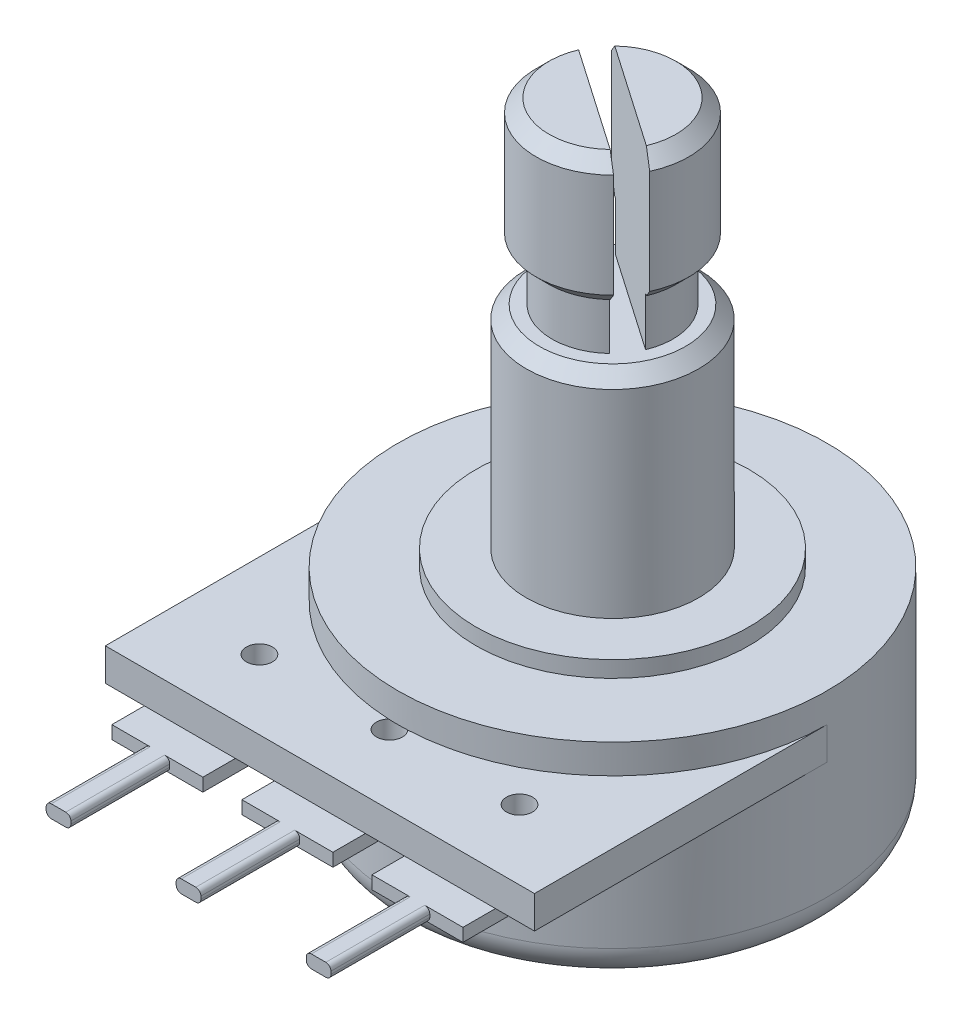
from build123d import *

# Parameters (mm, degrees)
SKETCH2_W           = 16.764
SKETCH2_H           = 1.27
BOSS_EXTRUDE1_DEPTH = 11.43
SKETCH3_R           = 0.508
BOSS_EXTRUDE2_DEPTH = 0.508
SKETCH5_R           = 8.382
SKETCH5_R_2         = 5.334
CUT_EXTRUDE2_DEPTH  = 15.875
LPATTERN1_COUNT     = 2
LPATTERN1_PITCH     = 5.08
LPATTERN2_COUNT     = 2
LPATTERN2_PITCH     = 5.08
SKETCH7_R           = 0.508
CUT_EXTRUDE3_DEPTH  = 1.27
CUT_EXTRUDE4_DEPTH  = 6.985
CHAMFER1_SIZE       = 0.508
FILLET1_R           = 1.27
FILLET2_R           = 0.2
SKETCH9_W           = 2
SKETCH9_H           = 3.195606775
CUT_EXTRUDE5_DEPTH  = 2
FILLET3_R           = 0.6


with BuildPart() as part:
    # Sketch1 → Base-Revolve (revolve)
    with BuildSketch(Plane.XY):
        Polygon((0, 0), (8.382, 0), (8.382, 8.89), (3.3655, 8.89), (3.3655, 17.145), (2.3622, 17.145), (2.3622, 19.05), (2.9845, 19.05), (2.9845, 24.13), (0, 24.13), align=None)
    revolve(axis=Axis((0, 0, 0), (0, -1, 0)))

    # Sketch2 → Boss-Extrude1 (add)
    with BuildSketch(Plane.XY):
        with Locations((0, 6.477)):
            Rectangle(SKETCH2_W, SKETCH2_H)
    extrude(amount=BOSS_EXTRUDE1_DEPTH)

    # Sketch3 → Boss-Extrude2 (add)
    with BuildSketch(Plane.XZ.offset(-5.842)):
        with BuildLine():
            Line((-1.778, 12.7), (-0.4826, 12.7))
            Line((-0.4826, 12.7), (-0.4826, 16.5608))
            Line((-0.4826, 16.5608), (0.4826, 16.5608))
            Line((0.4826, 16.5608), (0.4826, 12.7))
            Line((0.4826, 12.7), (1.778, 12.7))
            Line((1.778, 12.7), (1.778, 8.7122))
            ThreePointArc((1.778, 8.7122), (0, 6.9342), (-1.778, 8.7122))
            Line((-1.778, 8.7122), (-1.778, 12.7))
        make_face()
        with Locations((0, 8.7122)):
            Circle(SKETCH3_R, mode=Mode.SUBTRACT)
    boss_extrude2 = extrude(amount=BOSS_EXTRUDE2_DEPTH)

    # Sketch5 → Cut-Extrude2 (cut)
    with BuildSketch(Plane(origin=(0, 24.13, 0), x_dir=(-1, 0, 0), z_dir=(0, 1, 0))):
        Circle(SKETCH5_R)
        Circle(SKETCH5_R_2, mode=Mode.SUBTRACT)
    extrude(amount=-CUT_EXTRUDE2_DEPTH, mode=Mode.SUBTRACT)

    # LPattern1: Boss-Extrude2 ×2
    with Locations(*[(-i * LPATTERN1_PITCH, 0, 0) for i in range(1, LPATTERN1_COUNT)]):
        add(boss_extrude2)

    # LPattern2: Boss-Extrude2 ×2
    with Locations(*[(i * LPATTERN2_PITCH, 0, 0) for i in range(1, LPATTERN2_COUNT)]):
        add(boss_extrude2)

    # Sketch7 → Cut-Extrude3 (cut)
    with BuildSketch(Plane.XZ.offset(-5.842)):
        with Locations((-5.08, 8.7122)):
            Circle(SKETCH7_R)
        with Locations((0, 8.7122)):
            Circle(SKETCH7_R)
        with Locations((5.08, 8.7122)):
            Circle(SKETCH7_R)
    extrude(amount=-CUT_EXTRUDE3_DEPTH, mode=Mode.SUBTRACT)

    # Sketch8 → Cut-Extrude4 (cut)
    with BuildSketch(Plane(origin=(0, 24.13, 0), x_dir=(-1, 0, 0), z_dir=(0, 1, 0))):
        with BuildLine():
            Line((-2.708292046, 1.253951532), (2.13071284, -2.089809331))
            ThreePointArc((2.13071284, -2.089809331), (2.455332287, -1.696638916), (2.708292046, -1.253951532))
            Line((2.708292046, -1.253951532), (-2.13071284, 2.089809331))
            ThreePointArc((-2.13071284, 2.089809331), (-2.455332287, 1.696638916), (-2.708292046, 1.253951532))
        make_face()
    extrude(amount=-CUT_EXTRUDE4_DEPTH, mode=Mode.SUBTRACT)

    # Chamfer1
    chamfer1_edges = [part.edges().sort_by_distance(p)[0] for p in [
        (1.128744386, 24.13, -2.762820364),
        (-1.696638916, 24.13, 2.455332287),
        (1.128744386, 19.05, -2.762820364),
        (-1.696638916, 19.05, 2.455332287),
        (-3.3655, 17.145, 0),
    ]]
    chamfer(chamfer1_edges, length=CHAMFER1_SIZE)

    # Fillet1
    fillet1_edges = [part.edges().sort_by_distance(p)[0] for p in [
        (-8.382, 0, 0),
    ]]
    fillet(fillet1_edges, radius=FILLET1_R)

    # Fillet2
    fillet2_edges = [part.edges().sort_by_distance(p)[0] for p in [
        (4.5974, 5.842, 14.6304),
        (5.5626, 5.842, 14.6304),
        (5.5626, 5.334, 14.6304),
        (4.5974, 5.334, 14.6304),
        (-0.4826, 5.842, 14.6304),
        (0.4826, 5.842, 14.6304),
        (0.4826, 5.334, 14.6304),
        (-0.4826, 5.334, 14.6304),
        (-5.5626, 5.842, 14.6304),
        (-4.5974, 5.842, 14.6304),
        (-4.5974, 5.334, 14.6304),
        (-5.5626, 5.334, 14.6304),
    ]]
    fillet(fillet2_edges, radius=FILLET2_R)

    # Sketch9 → Cut-Extrude5 (cut)
    with BuildSketch(Plane.XZ):
        with Locations((0, -7.204164856)):
            Rectangle(SKETCH9_W, SKETCH9_H)
    extrude(amount=-CUT_EXTRUDE5_DEPTH, mode=Mode.SUBTRACT)

    # Fillet3
    fillet3_edges = [part.edges().sort_by_distance(p)[0] for p in [
        (0, 2, -8.382),
        (0, 0, -5.606361468),
        (0, 2, -5.606361468),
    ]]
    fillet(fillet3_edges, radius=FILLET3_R)


solid = part.part
